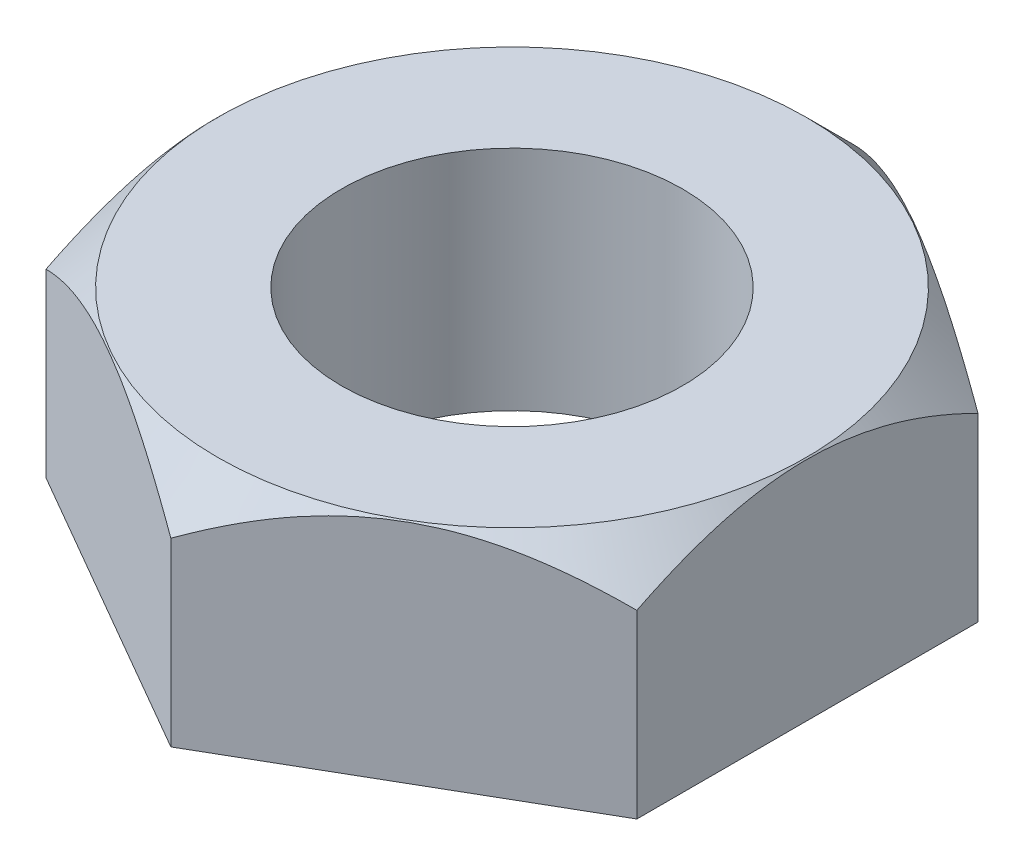
from build123d import *

# Parameters (mm, degrees)
SKETCH3_R           = 4.5
BOSS_EXTRUDE2_DEPTH = 6
SKETCH4_OUTSIDE_W   = 42.5
SKETCH4_OUTSIDE_H   = 44.912
SKETCH4_OUTSIDE_R   = 7.768332991
CUT_EXTRUDE1_DEPTH  = 10
CUT_EXTRUDE1_DRAFT  = -45


with BuildPart() as part:
    # Sketch3 → Boss-Extrude2 (new body)
    with BuildSketch(Plane(origin=(0, 0, 0), x_dir=(1, 0, 0), z_dir=(0, 1, 0))):
        Polygon((0, -9), (7.794228634, -4.5), (7.794228634, 4.5), (0, 9), (-7.794228634, 4.5), (-7.794228634, -4.5), align=None)
        with Locations(Location((0, 0, 0), (0, 0, 270))):  # turned: the seam where the file's is
            Circle(SKETCH3_R, mode=Mode.SUBTRACT)
    extrude(amount=BOSS_EXTRUDE2_DEPTH)


with BuildPart() as cut_extrude1_tool:
    # Sketch4 outside → Cut-Extrude1 (with draft: the straight prism first)
    with BuildSketch(Plane(origin=(0, 6, 0), x_dir=(1, 0, 0), z_dir=(0, 1, 0))):
        Rectangle(SKETCH4_OUTSIDE_W, SKETCH4_OUTSIDE_H)
        Circle(SKETCH4_OUTSIDE_R, mode=Mode.SUBTRACT)
    extrude(amount=-CUT_EXTRUDE1_DEPTH)
    # Cut-Extrude1: the draft: its side faces are tilted about the plane it starts from
    cut_extrude1_sides = [cut_extrude1_tool.faces().sort_by_distance(p)[0] for p in [
        (0, 1, 22.456),
        (21.25, 1, 0),
        (0, 1, -22.456),
        (-21.25, 1, 0),
        (-7.768332991, 1, 0),
    ]]
    draft(cut_extrude1_sides, Plane(origin=(0, 6, 0), x_dir=(1, 0, 0), z_dir=(0, 1, 0)), CUT_EXTRUDE1_DRAFT)


with BuildPart() as part_1:
    add(part.part)

    # Cut-Extrude1: cut by cut_extrude1_tool
    add(cut_extrude1_tool.part, mode=Mode.SUBTRACT)


solid = part_1.part
